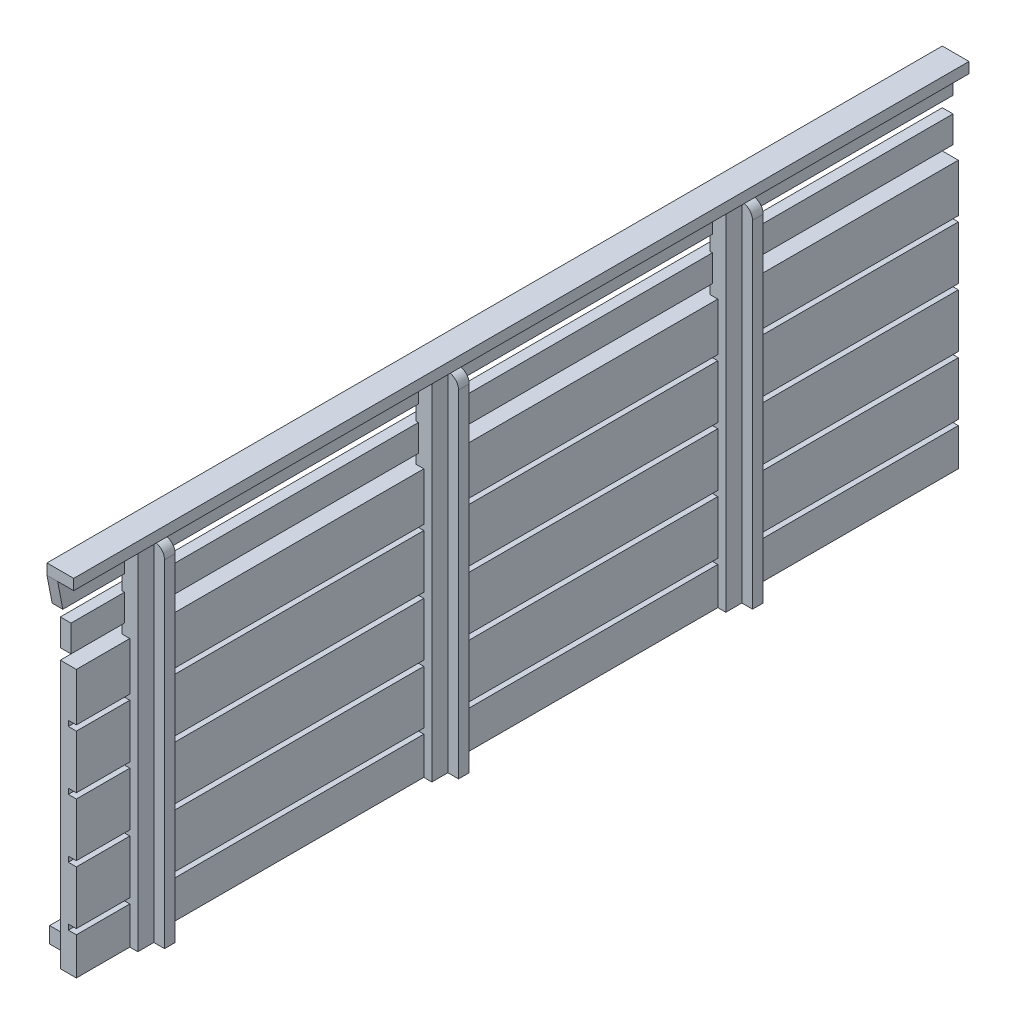
from build123d import *

# Parameters (mm, degrees)
SKETCH1_W             = 165
SKETCH1_H             = 50
BOSS_EXTRUDE1_DEPTH   = 3
SKETCH2_W             = 165
SKETCH2_H             = 1
CUT_EXTRUDE1_DEPTH    = 1.5
SKETCH3_W             = 5
SKETCH3_H             = 65
BOSS_EXTRUDE2_DEPTH   = 1.5
SKETCH4_W             = 2
SKETCH4_H             = 65
BOSS_EXTRUDE3_DEPTH   = 2
FILLET1_R             = 2
SKETCH5_W             = 165
SKETCH5_H             = 5
BOSS_EXTRUDE4_DEPTH   = 2
SKETCH5_W_2           = 167.5
BOSS_EXTRUDE4_2_DEPTH = 2
SKETCH7_W             = 165
SKETCH7_H             = 3
BOSS_EXTRUDE5_DEPTH   = 5
SKETCH8_W             = 5
SKETCH8_H             = 167.494782264
BOSS_EXTRUDE6_DEPTH   = 2
SKETCH12_W            = 5
SKETCH12_H            = 3
CUT_EXTRUDE3_DEPTH    = 3
CUT_EXTRUDE5_DEPTH    = 10


with BuildPart() as part:
    # Sketch1 → Boss-Extrude1 (new body)
    with BuildSketch(Plane(origin=(0, 0, 0), x_dir=(0, 0, -1), z_dir=(1, 0, 0))):
        Rectangle(SKETCH1_W, SKETCH1_H)
    extrude(amount=BOSS_EXTRUDE1_DEPTH)

    # Sketch2 → Cut-Extrude1 (cut)
    with BuildSketch(Plane(origin=(3, 0, 0), x_dir=(0, 0, -1), z_dir=(1, 0, 0))):
        with Locations((0, -17.5)):
            Rectangle(SKETCH2_W, SKETCH2_H)
        with Locations((0, -6.5)):
            Rectangle(SKETCH2_W, SKETCH2_H)
        with Locations((0, 4.5)):
            Rectangle(SKETCH2_W, SKETCH2_H)
        with Locations((0, 15.5)):
            Rectangle(SKETCH2_W, SKETCH2_H)
    extrude(amount=-CUT_EXTRUDE1_DEPTH, mode=Mode.SUBTRACT)

    # Sketch3 → Boss-Extrude2 (add, symmetric)
    with BuildSketch(Plane(origin=(3, 0, 0), x_dir=(0, 0, -1), z_dir=(1, 0, 0))):
        with Locations((-70, 7.5)):
            Rectangle(SKETCH3_W, SKETCH3_H)
        with Locations((40, 7.5)):
            Rectangle(SKETCH3_W, SKETCH3_H)
        with Locations((-15, 7.5)):
            Rectangle(SKETCH3_W, SKETCH3_H)
    extrude(amount=BOSS_EXTRUDE2_DEPTH, both=True)

    # Sketch4 → Boss-Extrude3 (add)
    with BuildSketch(Plane(origin=(4.5, 0, 0), x_dir=(0, 0, -1), z_dir=(1, 0, 0))):
        with Locations((41.5, 7.5)):
            Rectangle(SKETCH4_W, SKETCH4_H)
        with Locations((-13.5, 7.5)):
            Rectangle(SKETCH4_W, SKETCH4_H)
        with Locations((-68.5, 7.5)):
            Rectangle(SKETCH4_W, SKETCH4_H)
    extrude(amount=BOSS_EXTRUDE3_DEPTH)

    # Fillet1
    fillet1_edges = [part.edges().sort_by_distance(p)[0] for p in [
        (6.5, 40, 68.5),
        (6.5, 40, 13.5),
        (6.5, 40, -41.5),
    ]]
    fillet(fillet1_edges, radius=FILLET1_R)

    # Sketch7 → Boss-Extrude5 (add)
    with BuildSketch(Plane.ZY):
        with Locations((0, -23.5)):
            Rectangle(SKETCH7_W, SKETCH7_H)
    extrude(amount=BOSS_EXTRUDE5_DEPTH)



with BuildPart() as body_2:
    # Sketch5 → Boss-Extrude4 (new body)
    with BuildSketch(Plane.ZY):
        with Locations((0, 29.5)):
            Rectangle(SKETCH5_W, SKETCH5_H)
    extrude(amount=-BOSS_EXTRUDE4_DEPTH)


with BuildPart() as body_3:
    # Sketch5 → Boss-Extrude4 2 (new body)
    with BuildSketch(Plane.ZY):
        with Locations((1.25, 37.5)):
            Rectangle(SKETCH5_W_2, SKETCH5_H)
    extrude(amount=-BOSS_EXTRUDE4_2_DEPTH)


with BuildPart() as part_1:
    add(part.part)

    add(body_3.part)  # Boss-Extrude6 merges body 3
    # Sketch8 → Boss-Extrude6 (add)
    with BuildSketch(Plane(origin=(0, 40, 0), x_dir=(1, 0, 0), z_dir=(0, 1, 0))):
        with Locations((2.5, -1.247391132)):
            Rectangle(SKETCH8_W, SKETCH8_H)
    extrude(amount=BOSS_EXTRUDE6_DEPTH)

    # Sketch12 → Cut-Extrude3 (cut)
    with BuildSketch(Plane(origin=(0, -22, 0), x_dir=(1, 0, 0), z_dir=(0, 1, 0))):
        with Locations((-2.5, -81)):
            Rectangle(SKETCH12_W, SKETCH12_H)
    extrude(amount=-CUT_EXTRUDE3_DEPTH, mode=Mode.SUBTRACT)

    # Sketch13 → Cut-Extrude5 (cut)
    with BuildSketch(Plane(origin=(2, 0, 0), x_dir=(0, 0, -1), z_dir=(1, 0, 0))):
        Polygon((-82.5, 27), (-84.994782264, 40), (-86.356736261, 40), (-86.356736261, 27), align=None)
    extrude(amount=-CUT_EXTRUDE5_DEPTH, mode=Mode.SUBTRACT)


solid = Compound([body_2.part, part_1.part])
